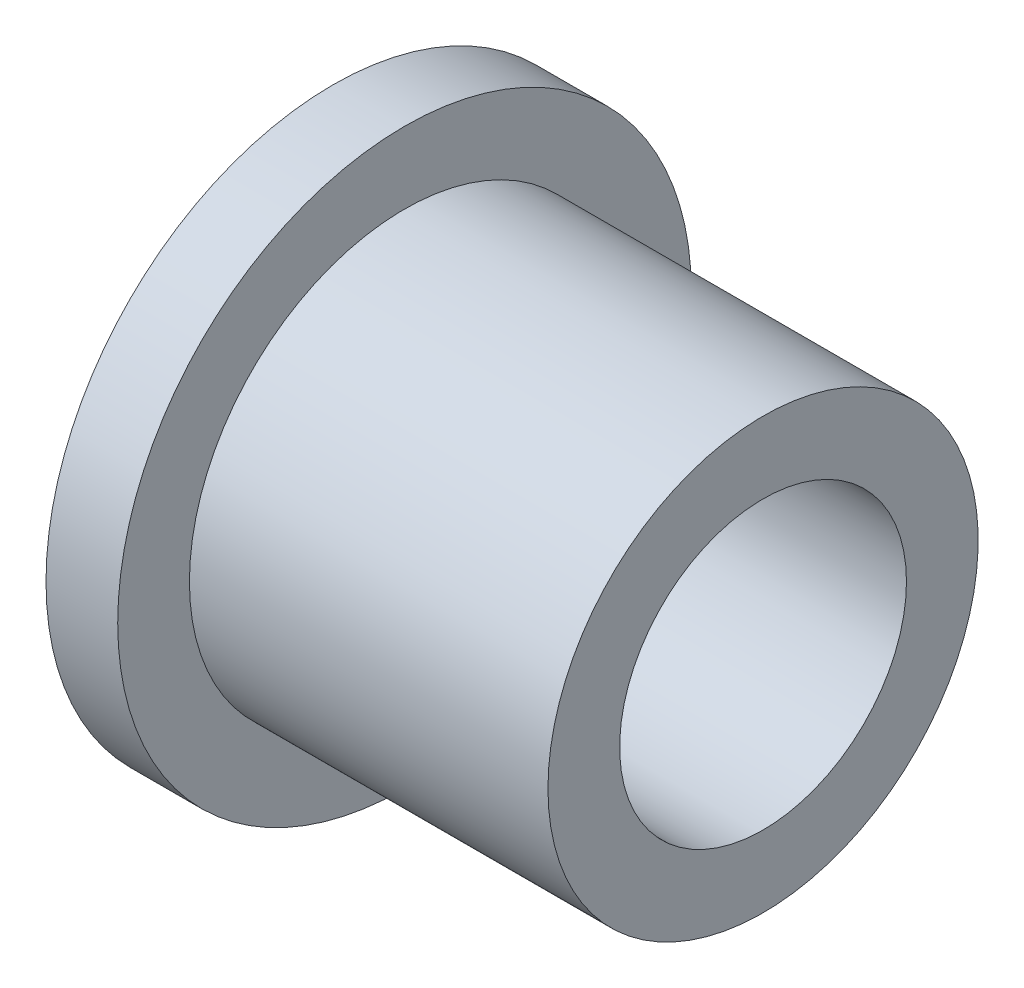
from build123d import *

# Parameters (mm, degrees)
SKETCH2_R      = 3.175
EXTRUDE1_DEPTH = 10.525


with BuildPart() as part:
    # Sketch1 → Revolve1 (revolve)
    with BuildSketch(Plane.XY, mode=Mode.PRIVATE) as revolve1_sk:
        Polygon((0, 0), (0, 6.35), (1.5875, 6.35), (1.5875, 4.7625), (9.525, 4.7625), (9.525, 0), align=None)
    revolve(revolve1_sk.sketch.rotate(Axis((0, 0, 0), (1, 0, 0)), 90), axis=Axis((0, 0, 0), (1, 0, 0)))  # turned: the seam where the file's is

    # Sketch2 → Extrude1 (cut, through all)
    with BuildSketch(Plane(origin=(9.525, 0, 0), x_dir=(0, 0, -1), z_dir=(1, 0, 0))):
        Circle(SKETCH2_R)
    extrude(amount=-EXTRUDE1_DEPTH, mode=Mode.SUBTRACT)


solid = part.part
